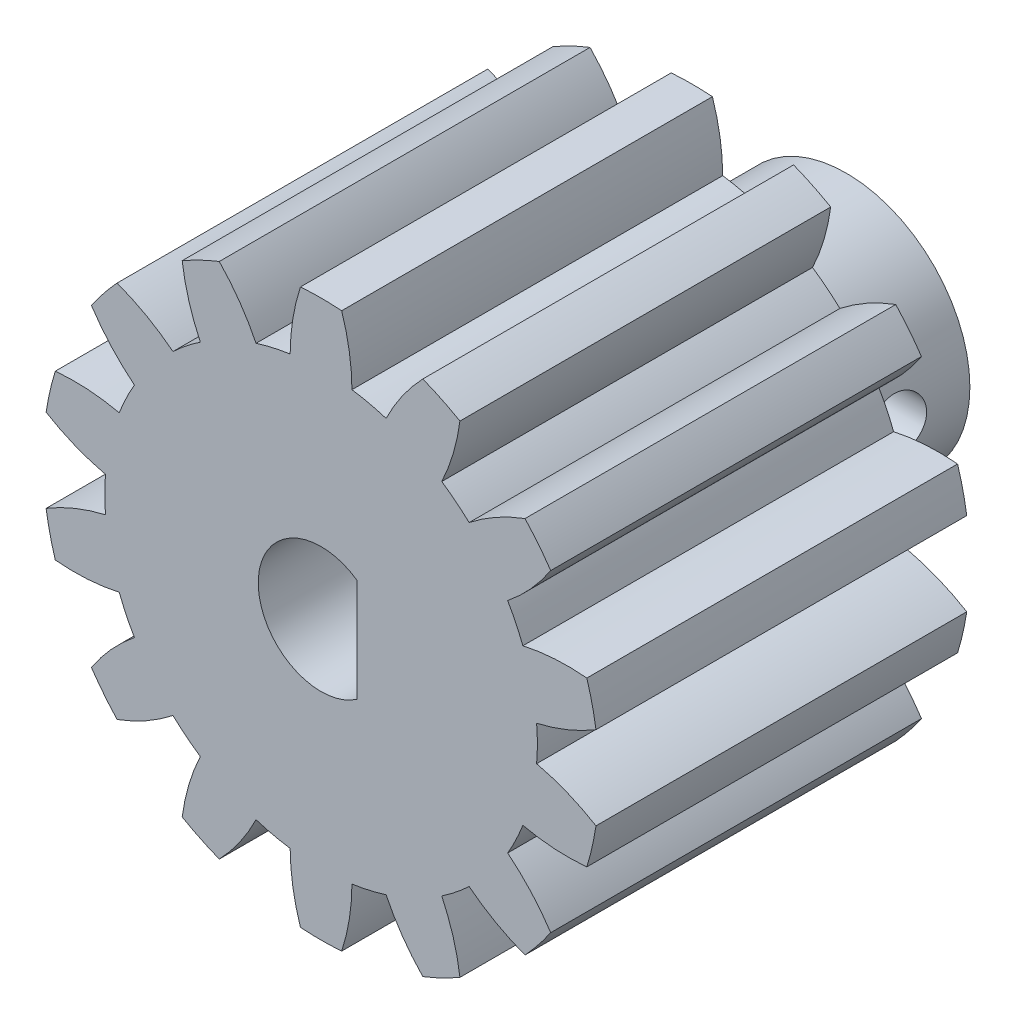
from build123d import *

# Parameters (mm, degrees)
SKETCH1_R               = 6
SKETCH1_R_2             = 3.05
BOSS_EXTRUDE1_DEPTH     = 7.5
SKETCH2_R               = 10.5
BOSS_EXTRUDE3_DEPTH     = 18
BOSS_EXTRUDE4_DEPTH     = 18
CIRPATTERN1_COUNT       = 14
SKETCH3_R               = 3.05
CUT_EXTRUDE1_DEPTH      = 19
SKETCH5_W               = 1.3
SKETCH5_H               = 8.98796618
BOSS_EXTRUDE5_DEPTH     = 25.5
SKETCH4_R               = 1.4
CUT_EXTRUDE2_DEPTH      = 1
CUT_EXTRUDE2_DEPTH_BACK = 38.540546983


with BuildPart() as part:
    # Sketch1 → Boss-Extrude1 (new body)
    with BuildSketch(Plane.XY):
        with Locations((-24.192657344, -27.82930415)):
            Circle(SKETCH1_R)
        with Locations((-24.192657344, -27.82930415)):
            Circle(SKETCH1_R_2, mode=Mode.SUBTRACT)
    extrude(amount=BOSS_EXTRUDE1_DEPTH)

    # Sketch2 → Boss-Extrude3 (add)
    with BuildSketch(Plane.XY.offset(7.5)):
        with Locations((-24.192657344, -27.82930415)):
            Circle(SKETCH2_R)
    extrude(amount=BOSS_EXTRUDE3_DEPTH)

    # Sketch2_4 → Boss-Extrude4 (add)
    with BuildSketch(Plane.XY.offset(7.5)):
        with BuildLine():
            ThreePointArc((-22.692657344, -17.436999304), (-22.822516009, -15.882132595), (-23.192657344, -14.366392132))
            ThreePointArc((-23.192657344, -14.366392132), (-24.192657344, -14.32930415), (-25.192657344, -14.366392132))
            ThreePointArc((-25.192657344, -14.366392132), (-25.562798679, -15.882132595), (-25.692657344, -17.436999304))
            ThreePointArc((-25.692657344, -17.436999304), (-24.192657344, -17.32930415), (-22.692657344, -17.436999304))
        make_face()
    boss_extrude4 = extrude(amount=BOSS_EXTRUDE4_DEPTH)

    # CirPattern1: Boss-Extrude4 ×14 about axis
    cirpattern1_axis = Axis((-24.192657344, -27.82930415, 0), (0, 0, 1))
    for i in range(1, CIRPATTERN1_COUNT):
        add(boss_extrude4.rotate(cirpattern1_axis, i * 360 / CIRPATTERN1_COUNT))

    # Sketch3 → Cut-Extrude1 (cut, through all)
    with BuildSketch(Plane(origin=(0, 0, 7.5), x_dir=(-1, 0, 0), z_dir=(0, 0, -1))):
        with Locations((24.192657344, -27.82930415)):
            Circle(SKETCH3_R)
    extrude(amount=-CUT_EXTRUDE1_DEPTH, mode=Mode.SUBTRACT)

    # Sketch5 → Boss-Extrude5 (add, through all)
    with BuildSketch(Plane(origin=(0, 0, 0), x_dir=(-1, 0, 0), z_dir=(0, 0, -1))):
        with Locations((21.792657344, -27.156324883)):
            Rectangle(SKETCH5_W, SKETCH5_H)
    extrude(amount=-BOSS_EXTRUDE5_DEPTH)

    # Sketch4 → Cut-Extrude2 (cut, two sides)
    with BuildSketch(Plane(origin=(0, 0, 0), x_dir=(0, 0, -1), z_dir=(1, 0, 0))) as cut_extrude2_sk:
        with Locations((-3.5, -27.82930415)):
            Circle(SKETCH4_R)
    extrude(amount=CUT_EXTRUDE2_DEPTH, mode=Mode.SUBTRACT)
    extrude(cut_extrude2_sk.sketch, amount=-CUT_EXTRUDE2_DEPTH_BACK, mode=Mode.SUBTRACT)


solid = part.part
